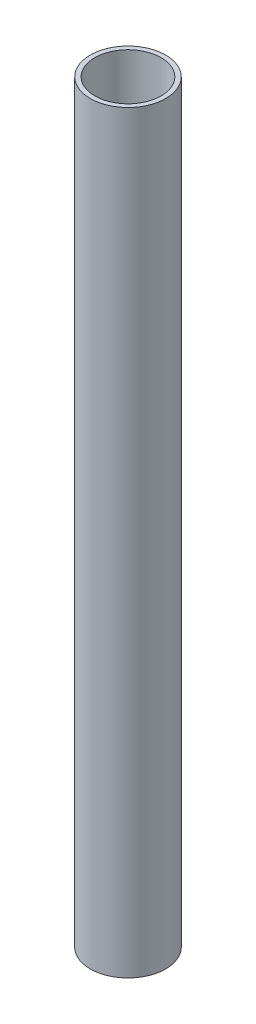
from build123d import *

# Parameters (mm, degrees)
SKETCH1_R           = 12.7
SKETCH1_R_2         = 11.176
BOSS_EXTRUDE1_DEPTH = 254


with BuildPart() as part:
    # Sketch1 → Boss-Extrude1 (new body)
    with BuildSketch(Plane(origin=(0, 0, 0), x_dir=(1, 0, 0), z_dir=(0, 1, 0))):
        Circle(SKETCH1_R)
        Circle(SKETCH1_R_2, mode=Mode.SUBTRACT)
    extrude(amount=BOSS_EXTRUDE1_DEPTH)


solid = part.part
